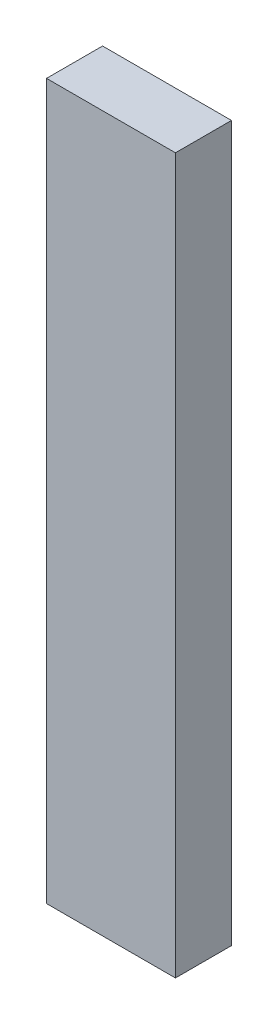
from build123d import *

# Parameters (mm, degrees)
SKETCH1_W           = 46
SKETCH1_H           = 20
BOSS_EXTRUDE1_DEPTH = 255


with BuildPart() as part:
    # Sketch1 → Boss-Extrude1 (new body)
    with BuildSketch(Plane(origin=(0, 0, 0), x_dir=(1, 0, 0), z_dir=(0, 1, 0))):
        Rectangle(SKETCH1_W, SKETCH1_H)
    extrude(amount=BOSS_EXTRUDE1_DEPTH)


solid = part.part
